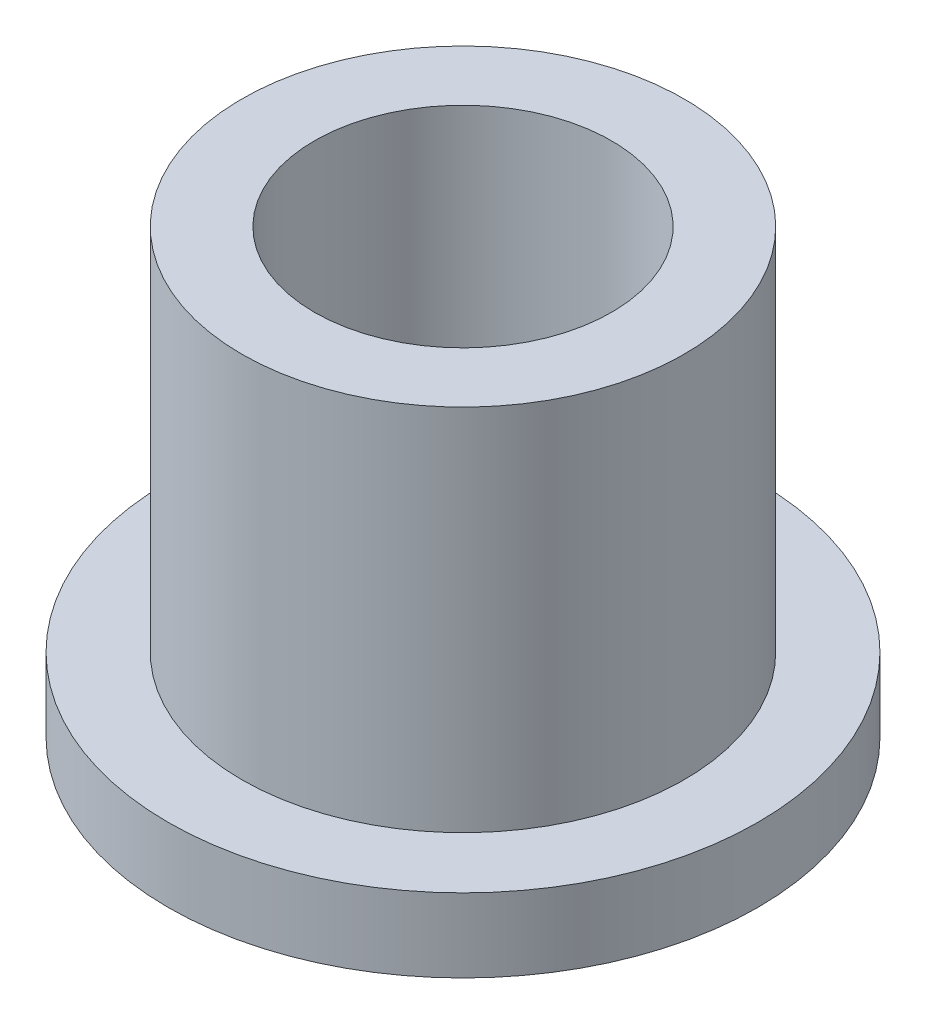
from build123d import *

# Parameters (mm, degrees)
SKETCH2_R           = 9.525
SKETCH2_R_2         = 6.4008
BOSS_EXTRUDE1_DEPTH = 19.05
SKETCH3_R           = 12.7
SKETCH3_R_2         = 9.525
BOSS_EXTRUDE2_DEPTH = 3.175


with BuildPart() as part:
    # Sketch2 → Boss-Extrude1 (new body)
    with BuildSketch(Plane(origin=(0, 0, 0), x_dir=(1, 0, 0), z_dir=(0, 1, 0))):
        Circle(SKETCH2_R)
        Circle(SKETCH2_R_2, mode=Mode.SUBTRACT)
    extrude(amount=BOSS_EXTRUDE1_DEPTH)

    # Sketch3 → Boss-Extrude2 (add)
    with BuildSketch(Plane(origin=(0, 0, 0), x_dir=(1, 0, 0), z_dir=(0, 1, 0))):
        Circle(SKETCH3_R)
        Circle(SKETCH3_R_2, mode=Mode.SUBTRACT)
    extrude(amount=BOSS_EXTRUDE2_DEPTH)


solid = part.part
